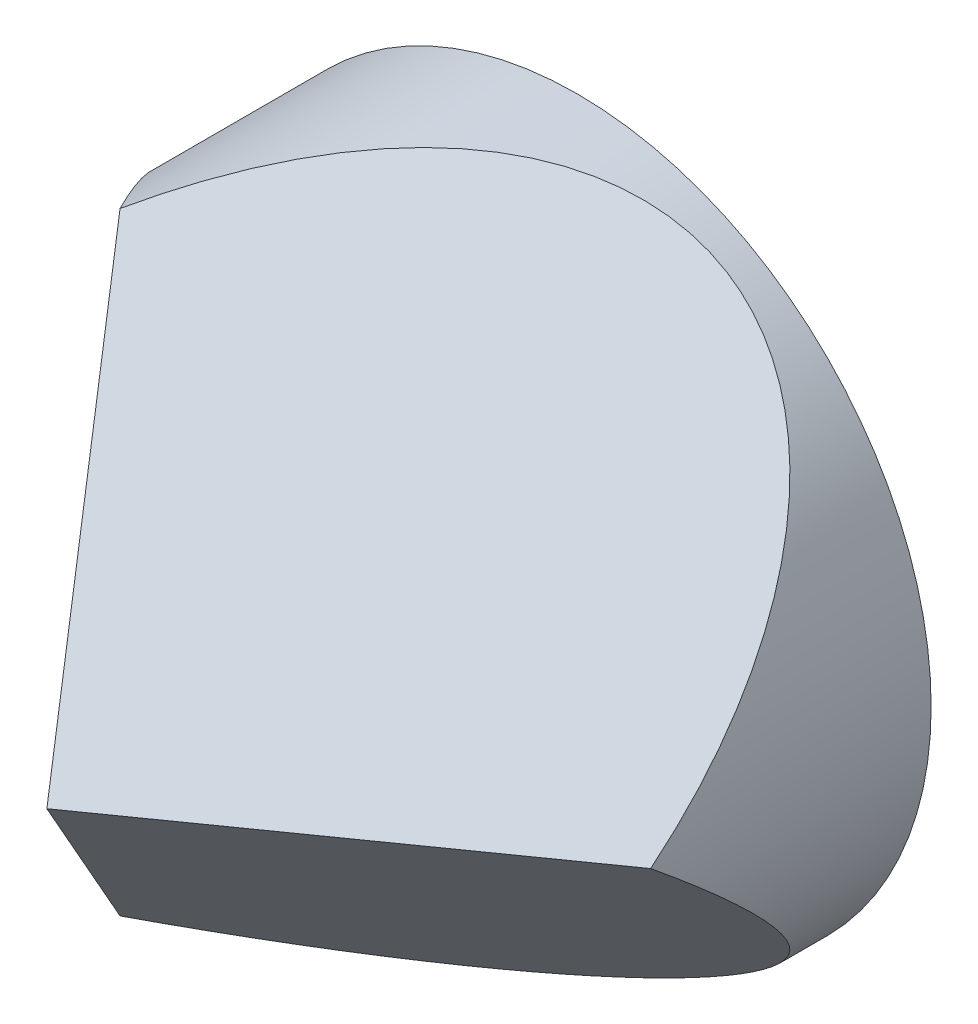
from build123d import *

# Parameters (mm, degrees)
SKETCH_1_R          = 19
EXTRUDE_1_DEPTH     = 28.5
CUT_EXTRUDE_1_DEPTH = 24.5
CUT_EXTRUDE_2_DEPTH = 37
CUT_EXTRUDE_3_DEPTH = 28.5


with BuildPart() as part:
    # 草图1 → 凸台-拉伸1 (new body)
    with BuildSketch(Plane.XY):
        Circle(SKETCH_1_R)
    extrude(amount=EXTRUDE_1_DEPTH)

    # 草图2 → 切除-拉伸1 (cut, symmetric)
    with BuildSketch(Plane(origin=(0, 0, 0), x_dir=(1, 0, 0), z_dir=(0, 1, 0))):
        Polygon((0, -28.5), (-22.967769977, 3.974585824), (-22.967769977, -37.518896878), (0, -37.518896878), align=None)
    extrude(amount=CUT_EXTRUDE_1_DEPTH, both=True, mode=Mode.SUBTRACT)

    # 草图4 → 切除-拉伸2 (cut, symmetric)
    with BuildSketch(Plane(origin=(0, 0, 0), x_dir=(0.5, 0.866025404, 0), z_dir=(0.866025404, -0.5, 0))):
        Polygon((0, 28.5), (68.254426356, -68.006288105), (68.254426356, 39.794321241), (0, 39.794321241), align=None)
    extrude(amount=CUT_EXTRUDE_2_DEPTH, both=True, mode=Mode.SUBTRACT)

    # 草图5 → 切除-拉伸3 (cut, symmetric)
    with BuildSketch(Plane(origin=(0, 0, 0), x_dir=(0.5, -0.866025404, 0), z_dir=(-0.866025404, -0.5, 0))):
        Polygon((0, 28.5), (25.869335206, -8.07716649), (25.869335206, 34.9969783), (-0.936236718, 34.9969783), align=None)
    extrude(amount=CUT_EXTRUDE_3_DEPTH, both=True, mode=Mode.SUBTRACT)


solid = part.part
